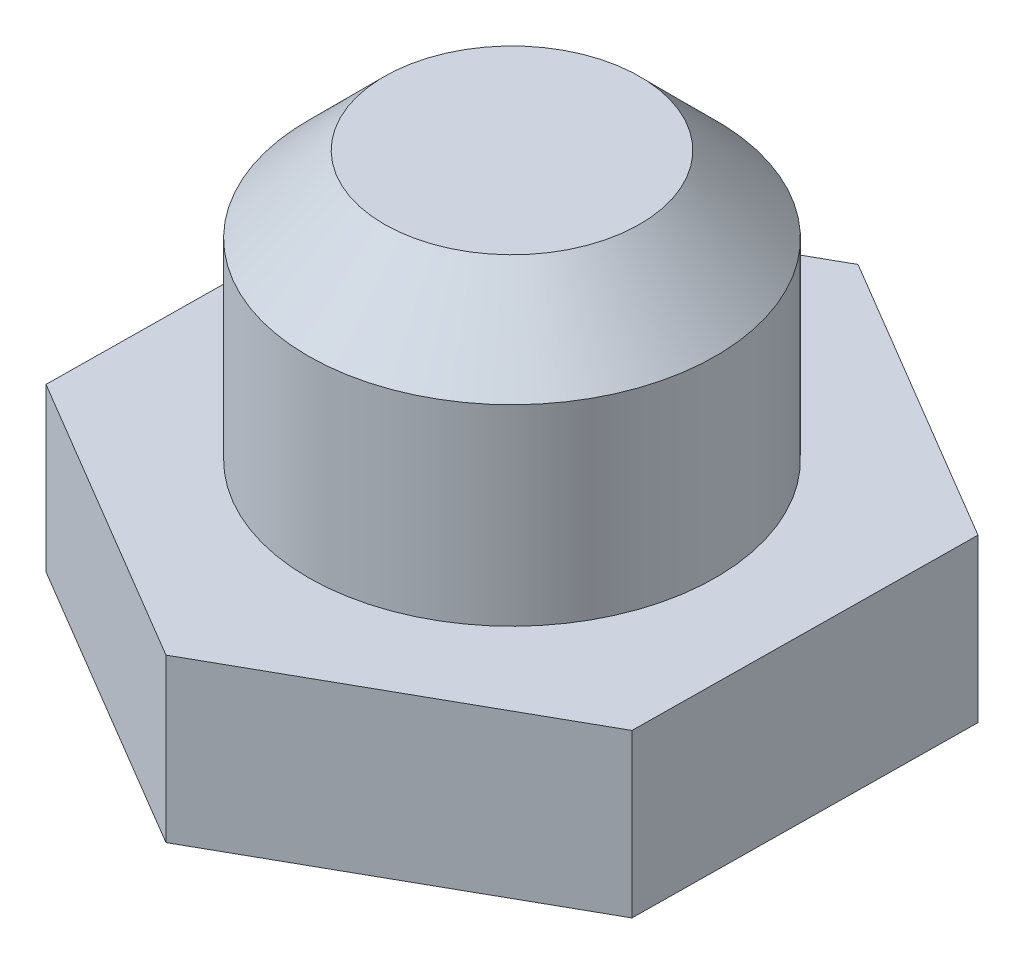
from build123d import *

# Parameters (mm, degrees)
SKETCH1_R           = 6.38048
BOSS_EXTRUDE1_DEPTH = 8.382
BOSS_EXTRUDE2_DEPTH = 5.08
CHAMFER1_SIZE       = 2.380000066


with BuildPart() as part:
    # Sketch1 → Boss-Extrude1 (new body)
    with BuildSketch(Plane(origin=(0, -69.088, -69.088), x_dir=(1, 0, 0), z_dir=(0, 1, 0))):
        with Locations((0, -69.088)):
            Circle(SKETCH1_R)
    extrude(amount=BOSS_EXTRUDE1_DEPTH)

    # Sketch1_11 → Boss-Extrude2 (add)
    with BuildSketch(Plane(origin=(0, -69.088, -69.088), x_dir=(1, 0, 0), z_dir=(0, 1, 0))):
        Polygon((9.209764962, -74.545302509), (9.33104509, -63.840760835), (0.121280128, -58.383458325), (-9.209764962, -63.630697491), (-9.33104509, -74.335239165), (-0.121280128, -79.792541675), align=None)
    extrude(amount=-BOSS_EXTRUDE2_DEPTH)

    # Chamfer1
    chamfer1_edges = [part.edges().sort_by_distance(p)[0] for p in [
        (-6.38048, -60.706, 0),
    ]]
    chamfer(chamfer1_edges, length=CHAMFER1_SIZE)


solid = part.part
